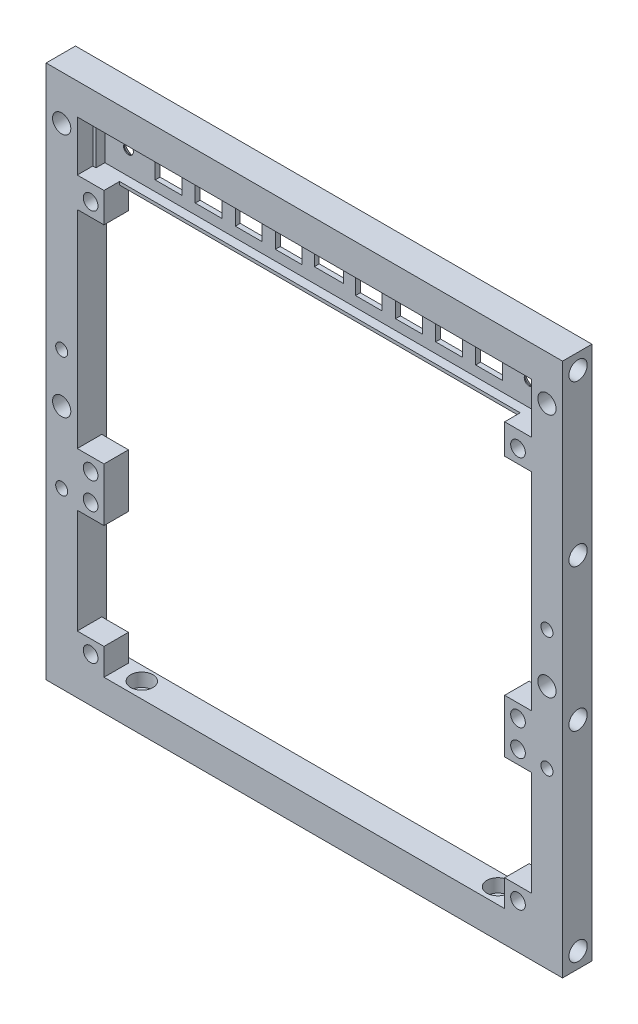
from build123d import *

# Parameters (mm, degrees)
SKETCH1_W                = 116
SKETCH1_H                = 120
SKETCH1_W_2              = 102
SKETCH1_H_2              = 106
BOSS_EXTRUDE1_DEPTH      = 7
SKETCH2_R                = 2.05
CUT_EXTRUDE1_DEPTH       = 6
SKETCH3_R                = 1.35
CUT_EXTRUDE2_DEPTH       = 128.208490283
SKETCH4_R                = 2.5
CUT_EXTRUDE3_DEPTH       = 3
SKETCH5_R                = 1.35
CUT_EXTRUDE4_DEPTH       = 84.743656476
SKETCH6_R                = 2.5
CUT_EXTRUDE5_DEPTH       = 3
SKETCH7_R                = 2.05
CUT_EXTRUDE6_DEPTH       = 84.743656476
CUT_EXTRUDE7_DEPTH       = 0.2
SKETCH9_W                = 2.7
SKETCH9_H                = 2.7
CUT_EXTRUDE8_DEPTH       = 0.2
SKETCH10_W               = 6
SKETCH10_H               = 6
BOSS_EXTRUDE2_DEPTH      = 5.5
SKETCH11_R               = 1.65
CUT_EXTRUDE9_DEPTH       = 84.631632771
SKETCH12_W               = 102
SKETCH12_H               = 12
BOSS_EXTRUDE3_DEPTH      = 1.5
SKETCH13_W               = 102
SKETCH13_H               = 12
SKETCH13_W_2             = 100.6
SKETCH13_H_2             = 10.6
BOSS_EXTRUDE4_DEPTH      = 2
SKETCH14_W               = 6
SKETCH14_H               = 6
SKETCH14_W_2             = 6.5
SKETCH14_H_2             = 4
CUT_EXTRUDE10_DEPTH      = 84.631632771
SKETCH15_R               = 1
BOSS_EXTRUDE5_DEPTH      = 2
CHAMFER1_SIZE            = 0.4
CHAMFER2_SIZE            = 0.4
CHAMFER3_SIZE            = 0.4
SKETCH16_W               = 6
SKETCH16_H               = 6
BOSS_EXTRUDE7_DEPTH      = 5.5
SKETCH17_R               = 1.65
CUT_EXTRUDE11_DEPTH      = 84.631632771
SKETCH18_R               = 1.1
CUT_EXTRUDE12_DEPTH      = 84.631632771
CUT_EXTRUDE12_DEPTH_BACK = 84.631632771
CHAMFER4_SIZE            = 1.3


with BuildPart() as part:
    # Sketch1 → Boss-Extrude1 (new body)
    with BuildSketch(Plane.XY):
        Rectangle(SKETCH1_W, SKETCH1_H)
        Rectangle(SKETCH1_W_2, SKETCH1_H_2, mode=Mode.SUBTRACT)
    extrude(amount=BOSS_EXTRUDE1_DEPTH)

    # Sketch2 → Cut-Extrude1 (cut)
    with BuildSketch(Plane.ZY.offset(58)):
        with Locations((3.5, -56.5)):
            Circle(SKETCH2_R)
        with Locations((3.5, 56.5)):
            Circle(SKETCH2_R)
        with Locations((3.5, 20.5)):
            Circle(SKETCH2_R)
        with Locations((3.5, -11.5)):
            Circle(SKETCH2_R)
    cut_extrude1 = extrude(amount=-CUT_EXTRUDE1_DEPTH, mode=Mode.SUBTRACT)

    # Mirror1: Cut-Extrude1 across plane
    add(cut_extrude1.mirror(Plane(origin=(0, 0, 0), x_dir=(0, 0, 1), z_dir=(1, 0, 0))), mode=Mode.SUBTRACT)

    # Sketch3 → Cut-Extrude2 (cut, through all)
    with BuildSketch(Plane(origin=(0, -53, 0), x_dir=(1, 0, 0), z_dir=(0, 1, 0))):
        with Locations(Location((40, -3.5, 0), (0, 0, 270))):
            Circle(SKETCH3_R)
        with Locations(Location((-40, -3.5, 0), (0, 0, 270))):
            Circle(SKETCH3_R)
    extrude(amount=-CUT_EXTRUDE2_DEPTH, mode=Mode.SUBTRACT)

    # Sketch4 → Cut-Extrude3 (cut)
    with BuildSketch(Plane(origin=(0, -53, 0), x_dir=(1, 0, 0), z_dir=(0, 1, 0))):
        with Locations(Location((40, -3.5, 0), (0, 0, 270))):
            Circle(SKETCH4_R)
        with Locations(Location((-40, -3.5, 0), (0, 0, 270))):
            Circle(SKETCH4_R)
    extrude(amount=-CUT_EXTRUDE3_DEPTH, mode=Mode.SUBTRACT)

    # Sketch5 → Cut-Extrude4 (cut, through all)
    with BuildSketch(Plane(origin=(0, 0, 0), x_dir=(-1, 0, 0), z_dir=(0, 0, -1))):
        with Locations((-54.5, 6)):
            Circle(SKETCH5_R)
        with Locations(Location((54.5, 6, 0), (0, 0, 180))):
            Circle(SKETCH5_R)
        with Locations((-54.5, -21)):
            Circle(SKETCH5_R)
        with Locations(Location((54.5, -21, 0), (0, 0, 180))):
            Circle(SKETCH5_R)
    extrude(amount=-CUT_EXTRUDE4_DEPTH, mode=Mode.SUBTRACT)

    # Sketch6 → Cut-Extrude5 (cut)
    with BuildSketch(Plane(origin=(0, 0, 0), x_dir=(-1, 0, 0), z_dir=(0, 0, -1))):
        with Locations((-54.5, 6)):
            Circle(SKETCH6_R)
        with Locations((54.5, 6)):
            Circle(SKETCH6_R)
        with Locations((-54.5, -21)):
            Circle(SKETCH6_R)
        with Locations((54.5, -21)):
            Circle(SKETCH6_R)
    extrude(amount=-CUT_EXTRUDE5_DEPTH, mode=Mode.SUBTRACT)

    # Sketch7 → Cut-Extrude6 (cut, through all)
    with BuildSketch(Plane(origin=(0, 0, 0), x_dir=(-1, 0, 0), z_dir=(0, 0, -1))):
        with Locations((-54.5, 50)):
            Circle(SKETCH7_R)
        with Locations((-54.5, -5)):
            Circle(SKETCH7_R)
    cut_extrude6 = extrude(amount=-CUT_EXTRUDE6_DEPTH, mode=Mode.SUBTRACT)

    # Mirror2: Cut-Extrude6 across plane
    add(cut_extrude6.mirror(Plane(origin=(0, 0, 0), x_dir=(0, 0, 1), z_dir=(1, 0, 0))), mode=Mode.SUBTRACT)

    # Sketch8 → Cut-Extrude7 (cut)
    with BuildSketch(Plane(origin=(0, 0, 3), x_dir=(-1, 0, 0), z_dir=(0, 0, -1))):
        with BuildLine():
            Line((-55.85, 3.895837459), (-55.85, 8.104162541))
            ThreePointArc((-55.85, 8.104162541), (-54.5, 8.5), (-53.15, 8.104162541))
            Line((-53.15, 8.104162541), (-53.15, 3.895837459))
            ThreePointArc((-53.15, 3.895837459), (-54.5, 3.5), (-55.85, 3.895837459))
        make_face()
        with BuildLine():
            Line((-55.85, -23.104162541), (-55.85, -18.895837459))
            ThreePointArc((-55.85, -18.895837459), (-54.5, -18.5), (-53.15, -18.895837459))
            Line((-53.15, -18.895837459), (-53.15, -23.104162541))
            ThreePointArc((-53.15, -23.104162541), (-54.5, -23.5), (-55.85, -23.104162541))
        make_face()
    cut_extrude7 = extrude(amount=-CUT_EXTRUDE7_DEPTH, mode=Mode.SUBTRACT)

    # Sketch9 → Cut-Extrude8 (cut)
    with BuildSketch(Plane(origin=(0, 0, 3.2), x_dir=(-1, 0, 0), z_dir=(0, 0, -1))):
        with Locations((-54.5, 6)):
            Rectangle(SKETCH9_W, SKETCH9_H)
        with Locations((-54.5, -21)):
            Rectangle(SKETCH9_W, SKETCH9_H)
    cut_extrude8 = extrude(amount=-CUT_EXTRUDE8_DEPTH, mode=Mode.SUBTRACT)

    # Mirror3: Cut-Extrude7, Cut-Extrude8 across plane
    add(cut_extrude7.mirror(Plane(origin=(0, 0, 0), x_dir=(0, 0, 1), z_dir=(1, 0, 0))), mode=Mode.SUBTRACT)
    add(cut_extrude8.mirror(Plane(origin=(0, 0, 0), x_dir=(0, 0, 1), z_dir=(1, 0, 0))), mode=Mode.SUBTRACT)

    # Sketch10 → Boss-Extrude2 (add)
    with BuildSketch(Plane.XY.offset(7)):
        with Locations((48, -50)):
            Rectangle(SKETCH10_W, SKETCH10_H)
        with Locations((48, -20.5)):
            Rectangle(SKETCH10_W, SKETCH10_H)
    boss_extrude2 = extrude(amount=-BOSS_EXTRUDE2_DEPTH)

    # Sketch11 → Cut-Extrude9 (cut, through all)
    with BuildSketch(Plane(origin=(0, 0, 1.5), x_dir=(-1, 0, 0), z_dir=(0, 0, -1))):
        with Locations((-48, -20.5)):
            Circle(SKETCH11_R)
        with Locations((-48, -50)):
            Circle(SKETCH11_R)
    cut_extrude9 = extrude(amount=-CUT_EXTRUDE9_DEPTH, mode=Mode.SUBTRACT)

    # Mirror4: Boss-Extrude2, Cut-Extrude9 across plane
    add(boss_extrude2.mirror(Plane(origin=(0, 0, 0), x_dir=(0, 0, 1), z_dir=(1, 0, 0))))
    add(cut_extrude9.mirror(Plane(origin=(0, 0, 0), x_dir=(0, 0, 1), z_dir=(1, 0, 0))), mode=Mode.SUBTRACT)

    # Sketch12 → Boss-Extrude3 (add)
    with BuildSketch(Plane(origin=(0, 0, 0), x_dir=(-1, 0, 0), z_dir=(0, 0, -1))):
        with Locations((0, 47)):
            Rectangle(SKETCH12_W, SKETCH12_H)
    extrude(amount=-BOSS_EXTRUDE3_DEPTH)

    # Sketch13 → Boss-Extrude4 (add)
    with BuildSketch(Plane.XY.offset(1.5)):
        with Locations((0, 47)):
            Rectangle(SKETCH13_W, SKETCH13_H)
        with Locations((0, 47)):
            Rectangle(SKETCH13_W_2, SKETCH13_H_2, mode=Mode.SUBTRACT)
    extrude(amount=BOSS_EXTRUDE4_DEPTH)

    # Sketch14 → Cut-Extrude10 (cut, through all)
    with BuildSketch(Plane.XY.offset(1.5)):
        with Locations((-36, 47)):
            Rectangle(SKETCH14_W, SKETCH14_H)
        with Locations((0, 47)):
            Rectangle(SKETCH14_W_2, SKETCH14_H_2)
        with Locations((9, 47)):
            Rectangle(SKETCH14_W, SKETCH14_H)
        with Locations((18, 47)):
            Rectangle(SKETCH14_W, SKETCH14_H)
        with Locations((27, 47)):
            Rectangle(SKETCH14_W, SKETCH14_H)
        with Locations((36, 47)):
            Rectangle(SKETCH14_W, SKETCH14_H)
        with Locations((-27, 47)):
            Rectangle(SKETCH14_W, SKETCH14_H)
        with Locations((-18, 47)):
            Rectangle(SKETCH14_W, SKETCH14_H)
        with Locations((-9, 47)):
            Rectangle(SKETCH14_W, SKETCH14_H)
    extrude(amount=-CUT_EXTRUDE10_DEPTH, mode=Mode.SUBTRACT)

    # Sketch15 → Boss-Extrude5 (add)
    with BuildSketch(Plane.XY.offset(1.5)):
        with Locations(Location((-45, 47, 0), (0, 0, 180))):
            Circle(SKETCH15_R)
        with Locations(Location((45, 47, 0), (0, 0, 180))):
            Circle(SKETCH15_R)
    extrude(amount=BOSS_EXTRUDE5_DEPTH)

    # Chamfer1
    chamfer1_edges = [part.edges().sort_by_distance(p)[0] for p in [
        (51, -6, 0),
        (0, -53, 0),
        (-51, -6, 0),
        (0, 41, 0),
    ]]
    chamfer(chamfer1_edges, length=CHAMFER1_SIZE)

    # Chamfer2
    chamfer2_edges = [part.edges().sort_by_distance(p)[0] for p in [
        (0, -60, 0),
        (-58, 0, 0),
        (0, 60, 0),
        (58, 0, 0),
    ]]
    chamfer(chamfer2_edges, length=CHAMFER2_SIZE)

    # Chamfer3
    chamfer3_edges = [part.edges().sort_by_distance(p)[0] for p in [
        (-6, 47, 0),
        (-9, 44, 0),
        (-12, 47, 0),
        (-9, 50, 0),
        (-15, 47, 0),
        (-18, 44, 0),
        (-21, 47, 0),
        (-18, 50, 0),
        (-24, 47, 0),
        (-27, 44, 0),
        (-30, 47, 0),
        (-27, 50, 0),
        (-33, 47, 0),
        (-36, 44, 0),
        (-39, 47, 0),
        (-36, 50, 0),
        (39, 47, 0),
        (36, 44, 0),
        (33, 47, 0),
        (36, 50, 0),
        (30, 47, 0),
        (27, 44, 0),
        (24, 47, 0),
        (27, 50, 0),
        (21, 47, 0),
        (18, 44, 0),
        (15, 47, 0),
        (18, 50, 0),
        (12, 47, 0),
        (9, 44, 0),
        (6, 47, 0),
        (9, 50, 0),
        (3.25, 47, 0),
        (0, 45, 0),
        (-3.25, 47, 0),
        (0, 49, 0),
    ]]
    chamfer(chamfer3_edges, length=CHAMFER3_SIZE)

    # Sketch16 → Boss-Extrude7 (add)
    with BuildSketch(Plane.XY.offset(7)):
        Polygon((-45, 41), (-45, 41.7), (-51, 41.7), (-51, 41), (-51, 35), (-45, 35), align=None)
        with Locations((-48, -14.5)):
            Rectangle(SKETCH16_W, SKETCH16_H)
        with Locations((48, -14.5)):
            Rectangle(SKETCH16_W, SKETCH16_H)
        Polygon((51, 41), (51, 35), (45, 35), (45, 41), (45, 41.7), (51, 41.7), align=None)
    extrude(amount=-BOSS_EXTRUDE7_DEPTH)

    # Sketch17 → Cut-Extrude11 (cut, through all)
    with BuildSketch(Plane(origin=(0, 0, 1.5), x_dir=(-1, 0, 0), z_dir=(0, 0, -1))):
        with Locations((-48, -14.5)):
            Circle(SKETCH17_R)
        with Locations((48, -14.5)):
            Circle(SKETCH17_R)
        with Locations((48, 38)):
            Circle(SKETCH17_R)
        with Locations((-48, 38)):
            Circle(SKETCH17_R)
    extrude(amount=-CUT_EXTRUDE11_DEPTH, mode=Mode.SUBTRACT)

    # Sketch18 → Cut-Extrude12 (cut, two sides)
    with BuildSketch(Plane.XY.offset(1.5)) as cut_extrude12_sk:
        with Locations((-45, 47)):
            Circle(SKETCH18_R)
        with Locations((45, 47)):
            Circle(SKETCH18_R)
    extrude(amount=CUT_EXTRUDE12_DEPTH, mode=Mode.SUBTRACT)
    extrude(cut_extrude12_sk.sketch, amount=-CUT_EXTRUDE12_DEPTH_BACK, mode=Mode.SUBTRACT)

    # Chamfer4
    chamfer4_edges = [part.edges().sort_by_distance(p)[0] for p in [
        (-46.1, 47, 0),
        (43.9, 47, 0),
    ]]
    chamfer(chamfer4_edges, length=CHAMFER4_SIZE)


solid = part.part
